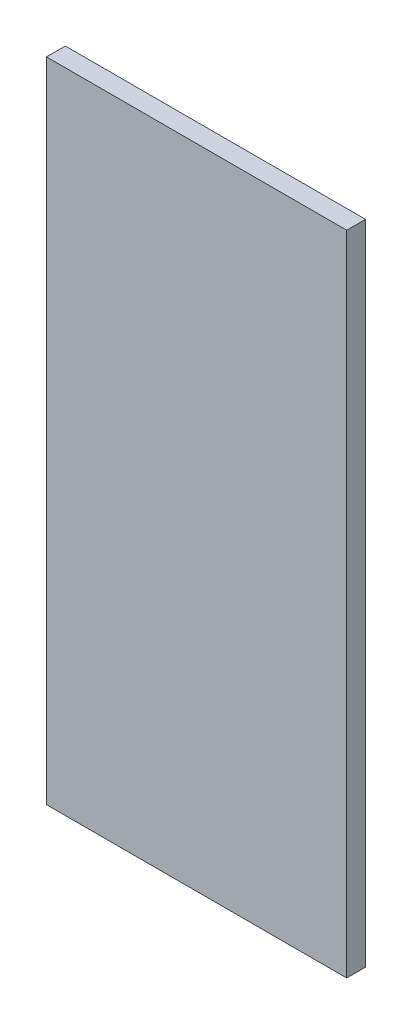
from build123d import *

# Parameters (mm, degrees)
SKETCH1_W           = 255
SKETCH1_H           = 550
BOSS_EXTRUDE1_DEPTH = 16


with BuildPart() as part:
    # Sketch1 → Boss-Extrude1 (new body)
    with BuildSketch(Plane.XY):
        Rectangle(SKETCH1_W, SKETCH1_H)
    extrude(amount=BOSS_EXTRUDE1_DEPTH)


solid = part.part
